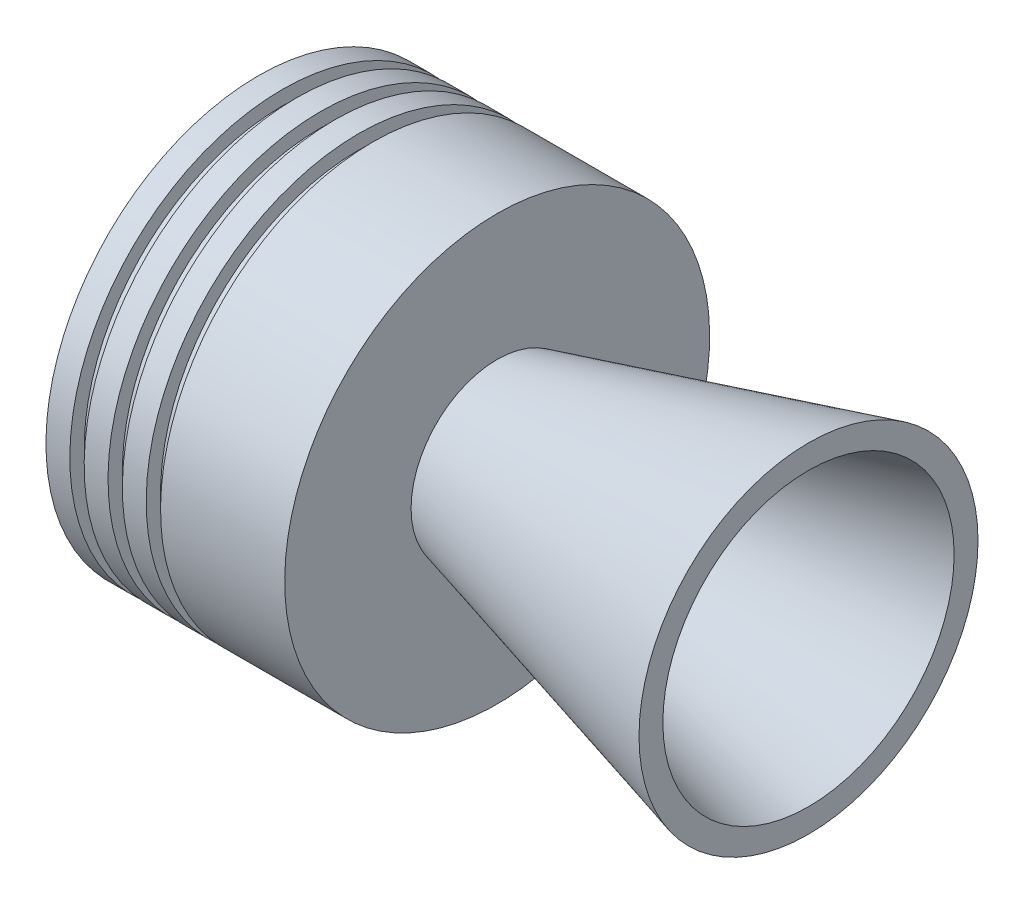
from build123d import *


with BuildPart() as part:
    # Sketch1 → Revolve1 (revolve)
    with BuildSketch(Plane.XY):
        Polygon((-82.105117767, 11.5), (0, 33.5), (0, 38.5), (-76.4, 18.028681698), (-76.4, 44.496311912), (-102.4, 44.496311912), (-102.4, 41.496311912), (-105.4, 41.496311912), (-105.4, 44.496311912), (-110.4, 44.496311912), (-110.4, 41.496311912), (-113.4, 41.496311912), (-113.4, 44.496311912), (-118.4, 44.496311912), (-118.4, 41.496311912), (-121.4, 41.496311912), (-121.4, 44.496311912), (-126.4, 44.496311912), (-126.4, 36.496311912), (-83.105117767, 11.5), align=None)
    revolve(axis=Axis((0, 0, 0), (-1, 0, 0)))

    # Sketch2 → Cut-Revolve1 (revolve, cut)
    with BuildSketch(Plane.XY):
        Polygon((-11.196152423, 0), (-11.196152423, 35.5), (-11.196152423, 56.271944123), (14.531335426, 56.271944123), (14.531335426, 0), align=None)
    revolve(axis=Axis((0, 0, 0), (-1, 0, 0)), mode=Mode.SUBTRACT)


solid = part.part
